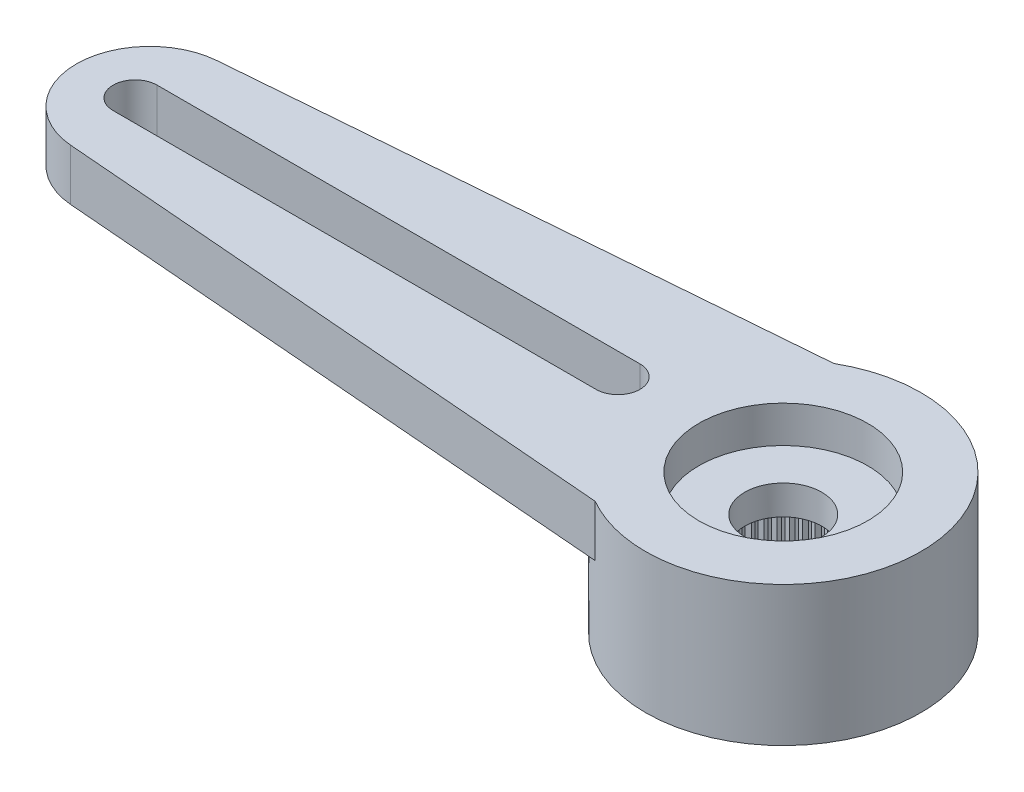
from build123d import *

# Parameters (mm, degrees)
RESSALTO_EXTRUS_O1_DEPTH = 1.4
ESBO_O2_R                = 3.75
RESSALTO_EXTRUS_O2_DEPTH = 2.4
FURO4_D                  = 1.2
FURO1_D                  = 4.95
FURO1_DEPTH              = 2
FURO2_D                  = 4.6
FURO2_DEPTH              = 1
FURO3_D                  = 2.1
RESSALTO_EXTRUS_O3_DEPTH = 2
PADR_OCIRCULAR1_COUNT    = 60
CUT_EXTRUDE1_DEPTH       = 1.4


with BuildPart() as part:
    # Esboço1 → Ressalto-extrusão1 (new body)
    with BuildSketch(Plane(origin=(0, 0, 0), x_dir=(1, 0, 0), z_dir=(0, 1, 0))):
        with BuildLine():
            Line((-17.41118274, 1.993494451), (-1.870828693, 3.25))
            ThreePointArc((-1.870828693, 3.25), (3.75, 0), (-1.870828693, -3.25))
            Line((-1.870828693, -3.25), (-17.41118274, -1.993494451))
            ThreePointArc((-17.41118274, -1.993494451), (-19.25, 0), (-17.41118274, 1.993494451))
        make_face()
    extrude(amount=-RESSALTO_EXTRUS_O1_DEPTH)

    # Esboço2 → Ressalto-extrusão2 (add)
    with BuildSketch(Plane.XZ.offset(1.4)):
        Circle(ESBO_O2_R)
    extrude(amount=RESSALTO_EXTRUS_O2_DEPTH)

    # Furo4 (through all)
    with Locations(Plane(origin=(0, 0, 0), x_dir=(1, 0, 0), z_dir=(0, 1, 0))):
        with Locations((-17.65, 0)):
            Hole(FURO4_D / 2)

    # Furo1
    with Locations(Plane(origin=(0, -3.8, 0), x_dir=(-1, 0, 0), z_dir=(0, -1, 0))):
        with Locations((0, 0)):
            Hole(FURO1_D / 2, depth=FURO1_DEPTH)

    # Furo2
    with Locations(Plane(origin=(0, 0, 0), x_dir=(1, 0, 0), z_dir=(0, 1, 0))):
        with Locations((0, 0)):
            Hole(FURO2_D / 2, depth=FURO2_DEPTH)

    # Furo3 (through all)
    with Locations(Plane(origin=(0, 0, 0), x_dir=(1, 0, 0), z_dir=(0, 1, 0))):
        with Locations((0, 0)):
            Hole(FURO3_D / 2)

    # Esboço11 → Ressalto-extrusão3 (add)
    with BuildSketch(Plane.XZ.offset(3.8)):
        with BuildLine():
            Line((-0.098056786, 2.473056786), (0, 2.375))
            Line((0, 2.375), (0.098056786, 2.473056786))
            ThreePointArc((0.098056786, 2.473056786), (0, 2.475), (-0.098056786, 2.473056786))
        make_face()
    ressalto_extrus_o3 = extrude(amount=-RESSALTO_EXTRUS_O3_DEPTH)

    # PadrãoCircular1: Ressalto-extrusão3 ×60 about axis
    padr_ocircular1_axis = Axis((0, 0, 0), (0, 1, 0))
    for i in range(1, PADR_OCIRCULAR1_COUNT):
        add(ressalto_extrus_o3.rotate(padr_ocircular1_axis, i * 360 / PADR_OCIRCULAR1_COUNT))

    # Sketch1 → Cut-Extrude1 (cut)
    with BuildSketch(Plane(origin=(0, 0, 0), x_dir=(1, 0, 0), z_dir=(0, 1, 0))):
        with BuildLine():
            Line((-17.65, 0.6), (-4.5, 0.6))
            ThreePointArc((-4.5, 0.6), (-3.9, 0), (-4.5, -0.6))
            Line((-4.5, -0.6), (-17.65, -0.6))
            ThreePointArc((-17.65, -0.6), (-18.25, 0), (-17.65, 0.6))
        make_face()
    extrude(amount=-CUT_EXTRUDE1_DEPTH, mode=Mode.SUBTRACT)


solid = part.part
